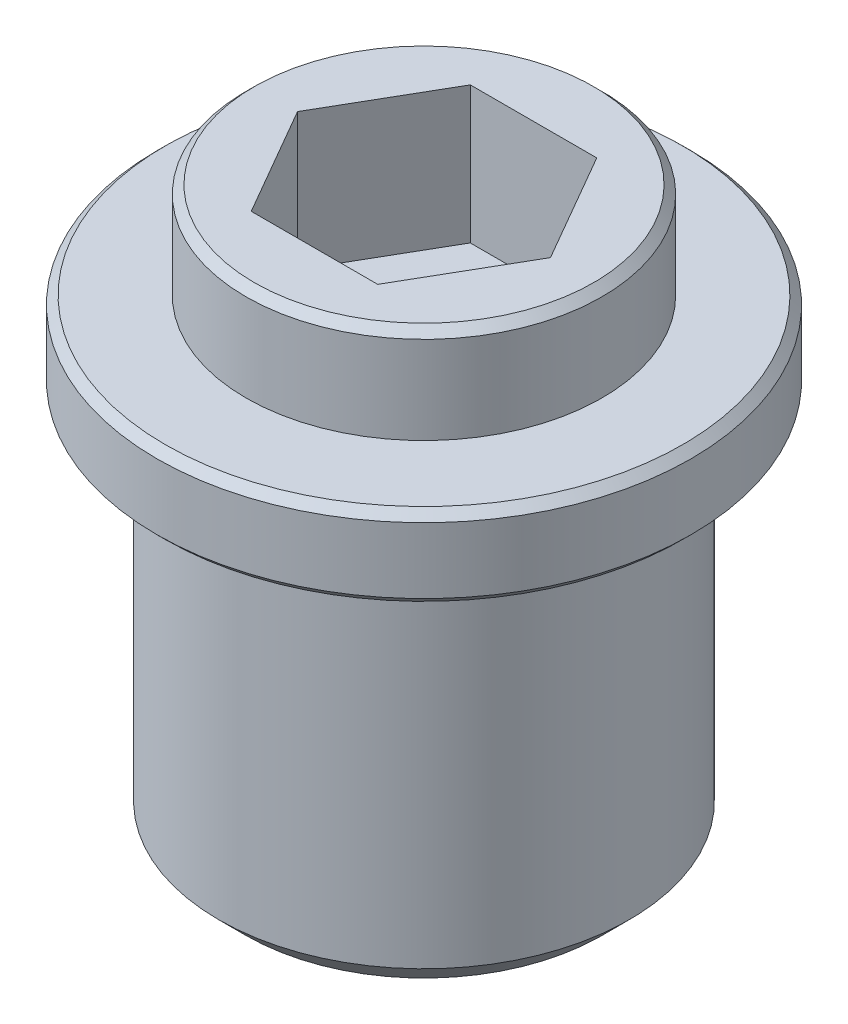
from build123d import *

# Parameters (mm, degrees)
ESQUISSE1_R             = 7.5
EXTRUSION1_DEPTH        = 14
ESQUISSE2_R             = 9.75
EXTRUSION2_DEPTH        = 3
ESQUISSE3_R             = 6.5
EXTRUSION3_DEPTH        = 6.5
ESQUISSE4_R             = 4.5
ENL_V_MAT_EXTRU_1_DEPTH = 12.5
ENL_V_MAT_EXTRU_2_DEPTH = 5
CHANFREIN1_SIZE         = 1
CHANFREIN2_SIZE         = 0.3


with BuildPart() as part:
    # Esquisse1 → Extrusion1 (new body)
    with BuildSketch(Plane(origin=(0, 0, 0), x_dir=(1, 0, 0), z_dir=(0, 1, 0))):
        with Locations(Location((0, 0, 0), (0, 0, 270))):  # turned: the seam where the file's is
            Circle(ESQUISSE1_R)
    extrude(amount=-EXTRUSION1_DEPTH)

    # Esquisse2 → Extrusion2 (add)
    with BuildSketch(Plane(origin=(0, 0, 0), x_dir=(-1, 0, 0), z_dir=(0, 1, 0))):
        with Locations(Location((0, 0, 0), (0, 0, 90))):  # turned: the seam where the file's is
            Circle(ESQUISSE2_R)
    extrude(amount=EXTRUSION2_DEPTH)

    # Esquisse3 → Extrusion3 (add)
    with BuildSketch(Plane(origin=(0, 0, 0), x_dir=(1, 0, 0), z_dir=(0, 1, 0))):
        with Locations(Location((0, 0, 0), (0, 0, 270))):  # turned: the seam where the file's is
            Circle(ESQUISSE3_R)
    extrude(amount=EXTRUSION3_DEPTH)

    # Esquisse4 → Enlèv. mat.-Extru.1 (cut)
    with BuildSketch(Plane.XZ.offset(14)):
        with Locations(Location((0, 0, 0), (0, 0, 270))):  # turned: the seam where the file's is
            Circle(ESQUISSE4_R)
    extrude(amount=-ENL_V_MAT_EXTRU_1_DEPTH, mode=Mode.SUBTRACT)

    # Esquisse5 → Enlèv. mat.-Extru.2 (cut)
    with BuildSketch(Plane(origin=(0, 6.5, 0), x_dir=(-1, 0, 0), z_dir=(0, 1, 0))):
        Polygon((-4.618802154, 0), (-2.309401077, -4), (2.309401077, -4), (4.618802154, 0), (2.309401077, 4), (-2.309401077, 4), align=None)
    extrude(amount=-ENL_V_MAT_EXTRU_2_DEPTH, mode=Mode.SUBTRACT)

    # Chanfrein1
    chanfrein1_edges = [part.edges().sort_by_distance(p)[0] for p in [
        (0, -14, -7.5),
    ]]
    chamfer(chanfrein1_edges, length=CHANFREIN1_SIZE)

    # Chanfrein2
    chanfrein2_edges = [part.edges().sort_by_distance(p)[0] for p in [
        (0, 6.5, -6.5),
        (0, 0, -9.75),
        (0, 3, -9.75),
    ]]
    chamfer(chanfrein2_edges, length=CHANFREIN2_SIZE)


solid = part.part
